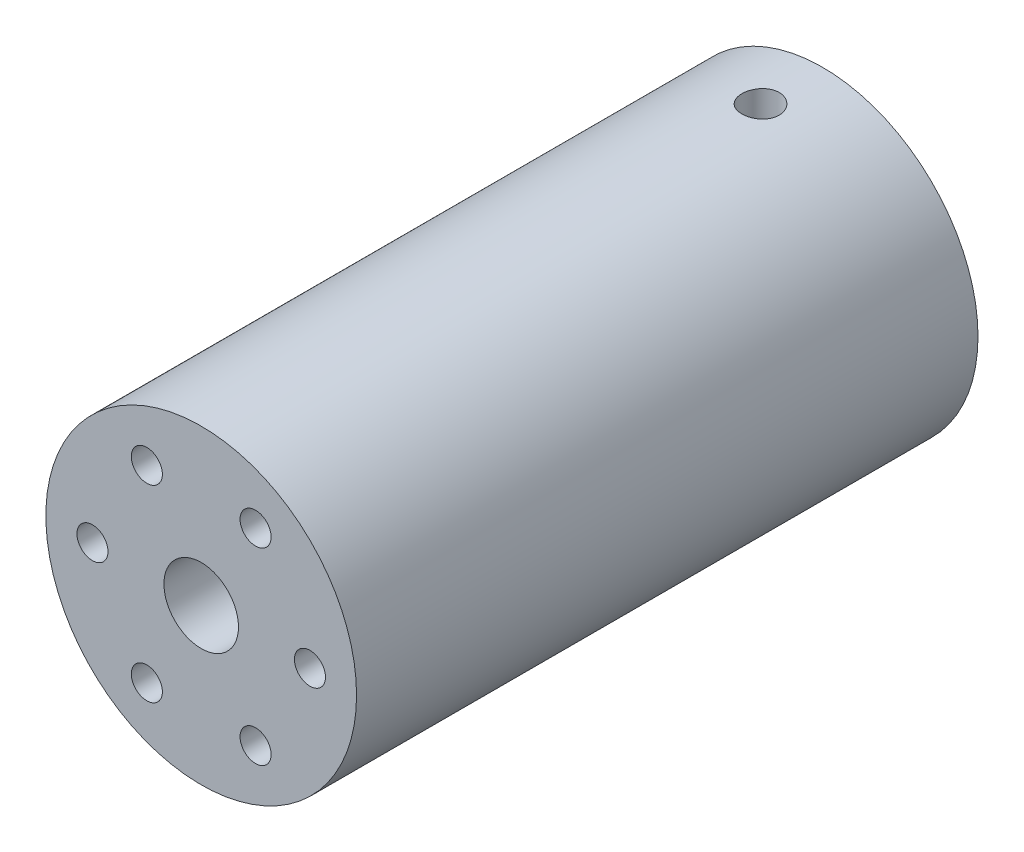
from build123d import *

# Parameters (mm, degrees)
CROQUIS1_R              = 12.5
SALIENTE_EXTRUIR1_DEPTH = 50
CROQUIS3_R              = 1.25
CROQUIS3_R_2            = 3
CORTAR_EXTRUIR1_DEPTH   = 51
CROQUIS6_R              = 1.5
CORTAR_EXTRUIR2_DEPTH   = 26


with BuildPart() as part:
    # Croquis1 → Saliente-Extruir1 (new body)
    with BuildSketch(Plane.XY):
        Circle(CROQUIS1_R)
    extrude(amount=SALIENTE_EXTRUIR1_DEPTH)

    # Croquis3 → Cortar-Extruir1 (cut, through all)
    with BuildSketch(Plane.XY.offset(50)):
        with Locations((8.75, 0)):
            Circle(CROQUIS3_R)
        with Locations((4.375, -7.577722283)):
            Circle(CROQUIS3_R)
        with Locations((-4.375, -7.577722283)):
            Circle(CROQUIS3_R)
        with Locations((-8.75, 0)):
            Circle(CROQUIS3_R)
        with Locations((-4.375, 7.577722283)):
            Circle(CROQUIS3_R)
        with Locations((4.375, 7.577722283)):
            Circle(CROQUIS3_R)
        Circle(CROQUIS3_R_2)
    extrude(amount=-CORTAR_EXTRUIR1_DEPTH, mode=Mode.SUBTRACT)

    # Croquis6 → Cortar-Extruir2 (cut, through all)
    with BuildSketch(Plane(origin=(0, 12.5, 0), x_dir=(1, 0, 0), z_dir=(0, 1, 0))):
        with Locations((0, -5)):
            Circle(CROQUIS6_R)
    extrude(amount=-CORTAR_EXTRUIR2_DEPTH, mode=Mode.SUBTRACT)


solid = part.part
